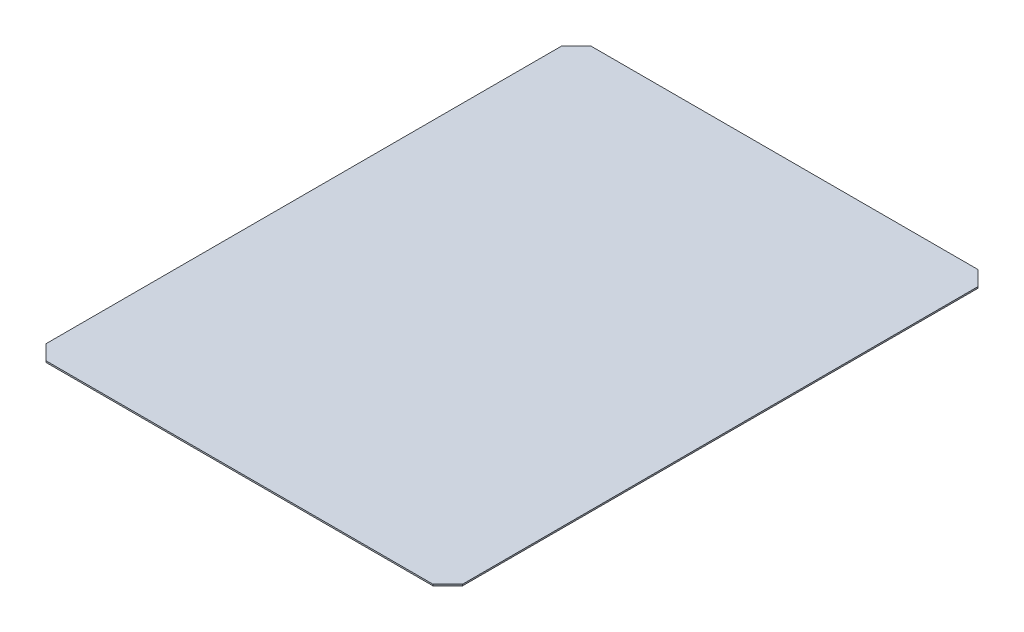
from build123d import *

# Parameters (mm, degrees)
ESQUISSE1_W             = 3100
ESQUISSE1_H             = 3690
BOSS_EXTRU_1_DEPTH      = 10
ESQUISSE2_W             = 140
ESQUISSE2_H             = 10
ENL_V_MAT_EXTRU_1_DEPTH = 3980.6
CHANFREIN1_SIZE         = 100


with BuildPart() as part:
    # Esquisse1 → Boss.-Extru.1 (new body)
    with BuildSketch(Plane(origin=(0, 0, 0), x_dir=(1, 0, 0), z_dir=(0, 1, 0))):
        with Locations((1550, 1845)):
            Rectangle(ESQUISSE1_W, ESQUISSE1_H)
    extrude(amount=BOSS_EXTRU_1_DEPTH)

    # Esquisse2 → Enlèv. mat.-Extru.1 (cut)
    with BuildSketch(Plane.XY):
        with Locations((70, 5)):
            Rectangle(ESQUISSE2_W, ESQUISSE2_H)
        with Locations((3030, 5)):
            Rectangle(ESQUISSE2_W, ESQUISSE2_H)
    extrude(amount=-ENL_V_MAT_EXTRU_1_DEPTH, mode=Mode.SUBTRACT)

    # Chanfrein1
    chanfrein1_edges = [part.edges().sort_by_distance(p)[0] for p in [
        (140, 5, -3690),
        (140, 5, 0),
        (2960, 5, -3690),
        (2960, 5, 0),
    ]]
    chamfer(chanfrein1_edges, length=CHANFREIN1_SIZE)


solid = part.part
